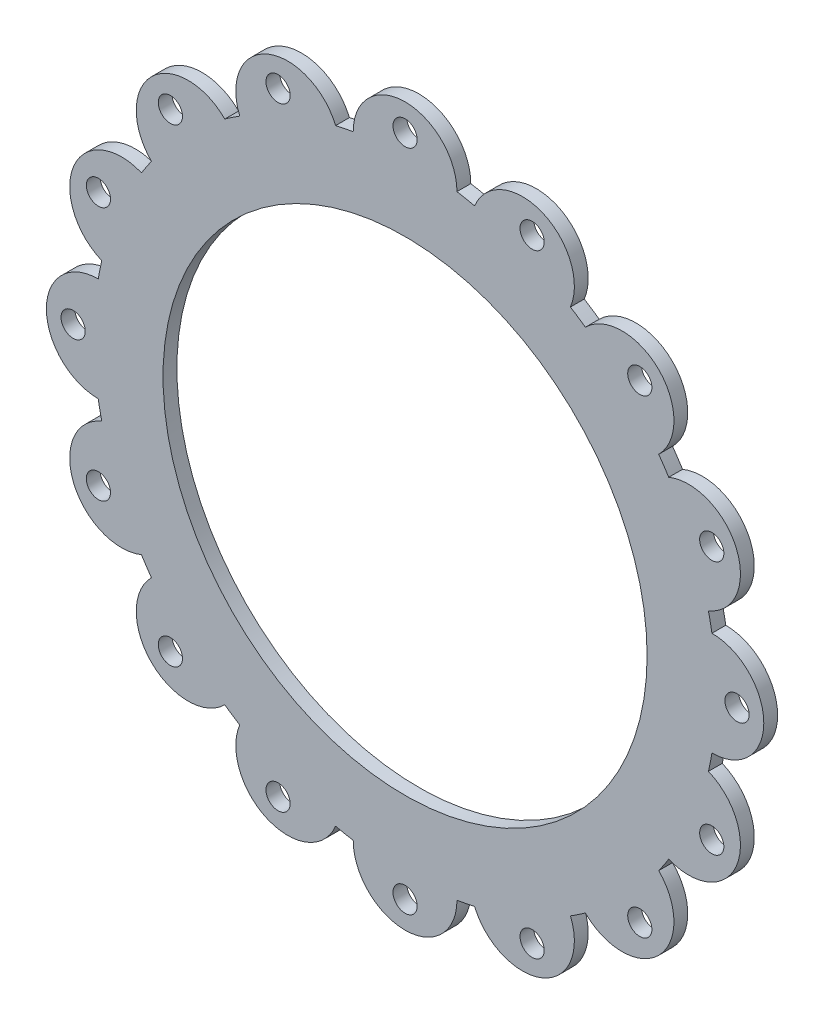
from build123d import *

# Parameters (mm, degrees)
SKETCH1_R           = 45
SKETCH1_R_2         = 35
BOSS_EXTRUDE1_DEPTH = 2
SKETCH2_R           = 1.75
BOSS_EXTRUDE2_DEPTH = 2
CIRPATTERN1_COUNT   = 16


with BuildPart() as part:
    # Sketch1 → Boss-Extrude1 (new body)
    with BuildSketch(Plane.XY):
        Circle(SKETCH1_R)
        Circle(SKETCH1_R_2, mode=Mode.SUBTRACT)
    extrude(amount=BOSS_EXTRUDE1_DEPTH)

    # Sketch2 → Boss-Extrude2 (add)
    with BuildSketch(Plane.XY):
        with BuildLine():
            ThreePointArc((7.5, 44.370598373), (0, 45), (-7.5, 44.370598373))
            ThreePointArc((-7.5, 44.370598373), (0, 51.870598373), (7.5, 44.370598373))
        make_face()
        with Locations((0, 48)):
            Circle(SKETCH2_R, mode=Mode.SUBTRACT)
    boss_extrude2 = extrude(amount=BOSS_EXTRUDE2_DEPTH)

    # CirPattern1: Boss-Extrude2 ×16 about axis
    cirpattern1_axis = Axis((0, 0, 0), (0, 0, 1))
    for i in range(1, CIRPATTERN1_COUNT):
        add(boss_extrude2.rotate(cirpattern1_axis, i * 360 / CIRPATTERN1_COUNT))


solid = part.part
